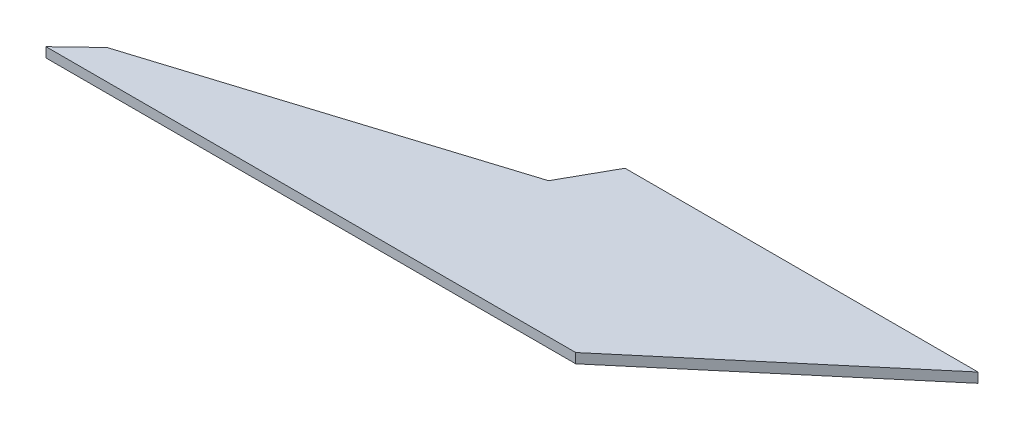
from build123d import *

# Parameters (mm, degrees)
BOSS_EXTRU_1_DEPTH = 2


with BuildPart() as part:
    # Esquisse1 → Boss.-Extru.1 (new body)
    with BuildSketch(Plane(origin=(0, 0, 0), x_dir=(1, 0, 0), z_dir=(0, 1, 0))):
        Polygon((152.559549771, 37.590321962), (80.54726419, 37.590321962), (74.951261467, 27.585139325), (6.366802996, 6.075349793), (0, 0), (108.0783974, 0), align=None)
    extrude(amount=BOSS_EXTRU_1_DEPTH)


solid = part.part
